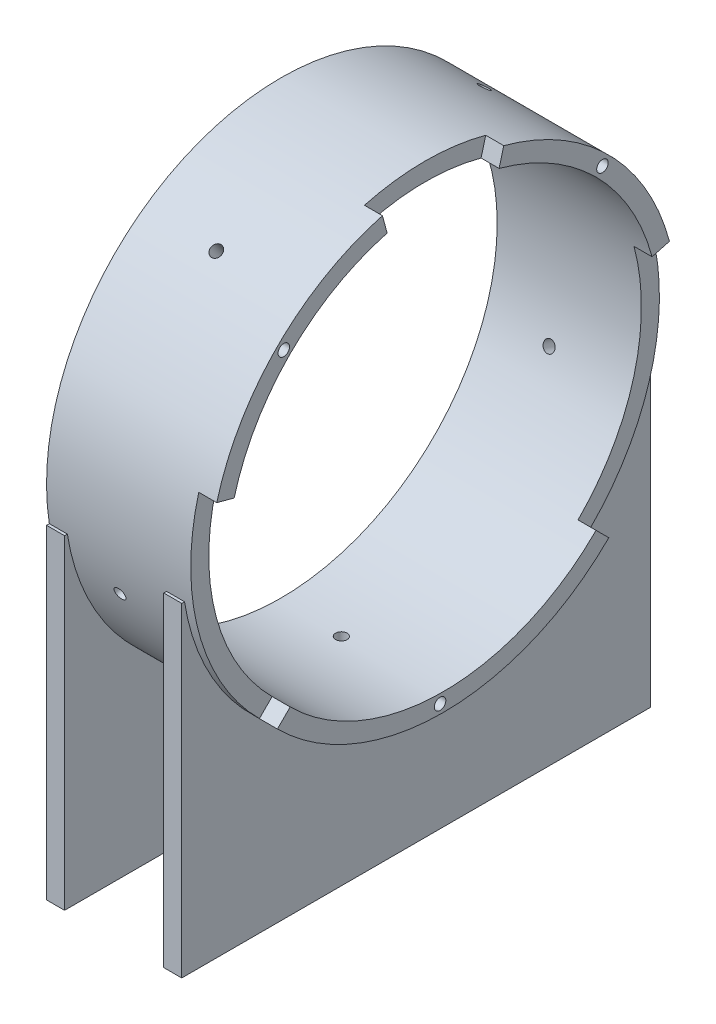
from build123d import *

# Parameters (mm, degrees)
SKETCH1_3_R                       = 260
SKETCH1_3_R_2                     = 240
BOSS_EXTRUDE1_DEPTH               = 180
BOSS_EXTRUDE2_DEPTH               = 20
BOSS_EXTRUDE3_DEPTH               = 20
CUT_EXTRUDE1_DEPTH                = 20
F_1_2_13_TAPPED_HOLE1_AT_2_COUNT  = 2
F_1_2_13_TAPPED_HOLE1_AT_2_PITCH  = 353.553390593
F_1_2_13_TAPPED_HOLE1_AT_3_COUNT  = 2
F_1_2_13_TAPPED_HOLE1_AT_3_PITCH  = 463.112622797
F_1_2_13_TAPPED_HOLE7_D           = 10.71626
F_1_2_13_TAPPED_HOLE7_DEPTH       = 45.9
F_1_2_13_TAPPED_HOLE7_CBORE_D     = 12.7
F_1_2_13_TAPPED_HOLE7_CBORE_DEPTH = 40
F_1_2_13_TAPPED_HOLE7_TIP         = 3.219489309


with BuildPart() as part:
    # Sketch1_3 → Boss-Extrude1 (new body)
    with BuildSketch(Plane(origin=(0, 0, 0), x_dir=(0, 0, -1), z_dir=(1, 0, 0))):
        with Locations(Location((0, 0, 0), (0, 0, 180))):
            Circle(SKETCH1_3_R)
        with Locations(Location((0, 0, 0), (0, 0, 180))):
            Circle(SKETCH1_3_R_2, mode=Mode.SUBTRACT)
    extrude(amount=BOSS_EXTRUDE1_DEPTH)

    # Sketch6 → Boss-Extrude2 (add)
    with BuildSketch(Plane(origin=(0, 0, 0), x_dir=(0, 0, -1), z_dir=(1, 0, 0))):
        with BuildLine():
            Line((-260, -40), (-260, -400))
            Line((-260, -400), (260, -400))
            Line((260, -400), (260, -40))
            Line((260, -40), (256.904651573, -40))
            ThreePointArc((256.904651573, -40), (0, -260), (-256.904651573, -40))
            Line((-256.904651573, -40), (-260, -40))
        make_face()
    extrude(amount=BOSS_EXTRUDE2_DEPTH)

    # Sketch11 → Boss-Extrude3 (add)
    with BuildSketch(Plane(origin=(150, 0, 0), x_dir=(0, 0, -1), z_dir=(1, 0, 0))):
        with BuildLine():
            Line((-260, -40), (-260, -400))
            Line((-260, -400), (260, -400))
            Line((260, -400), (260, -40))
            Line((260, -40), (256.904651573, -40))
            ThreePointArc((256.904651573, -40), (0, -260), (-256.904651573, -40))
            Line((-256.904651573, -40), (-260, -40))
        make_face()
    extrude(amount=-BOSS_EXTRUDE3_DEPTH)

    # Sketch23 → 1_2-13 Tapped Hole6 (revolve, cut)
    with BuildSketch(Plane(origin=(70.297889329, -259.97605488, 3.528581758), x_dir=(0, -0.013571468301340803, -0.9999079033831796), z_dir=(1, 0, 0))):
        Polygon((0, 0), (0, 33.219489309), (5.35813, 30), (5.35813, 40), (6.35, 40), (6.35, 0), align=None)
    revolve(axis=Axis((70.297889329, -266.325470066, 3.614760582), (0, 0.9999079033831795, -0.013571468301340804)), mode=Mode.SUBTRACT)

    # Sketch23 at point 2 (carried to point 2, square into its face) → 1_2-13 Tapped Hole6 at 2 (revolve, cut)
    with BuildSketch(Plane(origin=(69.980761371, -76.555334809, 248.473903483), x_dir=(0, -0.955668758, -0.294443925), z_dir=(1, 0, 0))):
        Polygon((0, 0), (0, 33.219489309), (5.35813, 30), (5.35813, 40), (6.35, 40), (6.35, 0), align=None)
    revolve(axis=Axis((69.980761371, -78.425053736, 254.542400096), (0, 0.294443925, -0.955668758)), mode=Mode.SUBTRACT)

    # Sketch23 at point 3 (carried to point 3, square into its face) → 1_2-13 Tapped Hole6 at 3 (revolve, cut)
    with BuildSketch(Plane(origin=(70.133454805, 208.161719285, -155.784141119), x_dir=(0, 0.599169917, 0.80062189), z_dir=(1, 0, 0))):
        Polygon((0, 0), (0, 33.219489309), (5.35813, 30), (5.35813, 40), (6.35, 40), (6.35, 0), align=None)
    revolve(axis=Axis((70.133454805, 213.245668284, -159.588870095), (0, -0.80062189, 0.599169917)), mode=Mode.SUBTRACT)

    # Sketch23 at point 4 (carried to point 4, square into its face) → 1_2-13 Tapped Hole6 at 4 (revolve, cut)
    with BuildSketch(Plane(origin=(70.173353325, -83.043025916, -246.38152497), x_dir=(0, 0.947621301, -0.319396101), z_dir=(1, 0, 0))):
        Polygon((0, 0), (0, 33.219489309), (5.35813, 30), (5.35813, 40), (6.35, 40), (6.35, 0), align=None)
    revolve(axis=Axis((70.173353325, -85.071191161, -252.398920232), (0, 0.319396101, 0.947621301)), mode=Mode.SUBTRACT)

    # Sketch23 at point 5 (carried to point 5, square into its face) → 1_2-13 Tapped Hole6 at 5 (revolve, cut)
    with BuildSketch(Plane(origin=(81.046534223, 210.414311033, 152.72792054), x_dir=(0, -0.587414938, 0.809285914), z_dir=(1, 0, 0))):
        Polygon((0, 0), (0, 33.219489309), (5.35813, 30), (5.35813, 40), (6.35, 40), (6.35, 0), align=None)
    revolve(axis=Axis((81.046534223, 215.553276588, 156.458005394), (0, -0.809285914, -0.587414938)), mode=Mode.SUBTRACT)

    # Sketch25 → Cut-Extrude1 (cut)
    with BuildSketch(Plane(origin=(180, 0, 0), x_dir=(0, 0, -1), z_dir=(1, 0, 0))):
        with BuildLine():
            Line((-169.705627485, -169.705627485), (-183.847763109, -183.847763109))
            ThreePointArc((-183.847763109, -183.847763109), (-225.166604984, -130), (-251.140714835, -67.292951727))
            ThreePointArc((-251.140714835, -67.292951727), (-260, 0), (-251.140714835, 67.292951727))
            Line((-251.140714835, 67.292951727), (-231.822198309, 62.116570825))
            ThreePointArc((-231.822198309, 62.116570825), (-240, 0), (-231.822198309, -62.116570825))
            ThreePointArc((-231.822198309, -62.116570825), (-207.846096908, -120), (-169.705627485, -169.705627485))
        make_face()
        with BuildLine():
            Line((169.705627485, -169.705627485), (183.847763109, -183.847763109))
            ThreePointArc((183.847763109, -183.847763109), (225.166604984, -130), (251.140714835, -67.292951727))
            ThreePointArc((251.140714835, -67.292951727), (260, 0), (251.140714835, 67.292951727))
            Line((251.140714835, 67.292951727), (231.822198309, 62.116570825))
            ThreePointArc((231.822198309, 62.116570825), (240, 0), (231.822198309, -62.116570825))
            ThreePointArc((231.822198309, -62.116570825), (207.846096908, -120), (169.705627485, -169.705627485))
        make_face()
        with BuildLine():
            Line((62.116570825, 231.822198309), (67.292951727, 251.140714835))
            ThreePointArc((67.292951727, 251.140714835), (0, 260), (-67.292951727, 251.140714835))
            Line((-67.292951727, 251.140714835), (-62.116570825, 231.822198309))
            ThreePointArc((-62.116570825, 231.822198309), (0, 240), (62.116570825, 231.822198309))
        make_face()
    extrude(amount=-CUT_EXTRUDE1_DEPTH, mode=Mode.SUBTRACT)

    # Sketch31 → 1_2-13 Tapped Hole1 (revolve, cut)
    with BuildSketch(Plane(origin=(180, 176.776695297, -176.776695297), x_dir=(0, 0, -1), z_dir=(0, 1, 0))):
        Polygon((0, 0), (0, 53.219489309), (5.35813, 50), (5.35813, 64.5), (6.35, 64.5), (6.35, 0), align=None)
    f_1_2_13_tapped_hole1 = revolve(axis=Axis((186.35, 176.776695297, -176.776695297), (-1, 0, 0)), mode=Mode.SUBTRACT)

    # 1_2-13 Tapped Hole1 at 2: 1_2-13 Tapped Hole1 ×2
    with Locations(*[(0, 0, i * F_1_2_13_TAPPED_HOLE1_AT_2_PITCH) for i in range(1, F_1_2_13_TAPPED_HOLE1_AT_2_COUNT)]):
        add(f_1_2_13_tapped_hole1, mode=Mode.SUBTRACT)

    # 1_2-13 Tapped Hole1 at 3: 1_2-13 Tapped Hole1 ×2
    with Locations(*[Vector(0, -0.9212531823667619, 0.3889634609820231) * (i * F_1_2_13_TAPPED_HOLE1_AT_3_PITCH) for i in range(1, F_1_2_13_TAPPED_HOLE1_AT_3_COUNT)]):
        add(f_1_2_13_tapped_hole1, mode=Mode.SUBTRACT)

    # 1_2-13 Tapped Hole7
    with Locations(Plane(origin=(140, -400, 250), x_dir=(0, 0, -1), z_dir=(0, -1, 0))):
        with Locations((0, 0), (0, -130), (500, -130), (500, 0)):
            CounterBoreHole(F_1_2_13_TAPPED_HOLE7_D / 2, F_1_2_13_TAPPED_HOLE7_CBORE_D / 2, F_1_2_13_TAPPED_HOLE7_CBORE_DEPTH, depth=F_1_2_13_TAPPED_HOLE7_DEPTH)
            with Locations((0, 0, -(F_1_2_13_TAPPED_HOLE7_DEPTH + F_1_2_13_TAPPED_HOLE7_TIP / 2))):  # 118° drill point
                Cone(0, F_1_2_13_TAPPED_HOLE7_D / 2, F_1_2_13_TAPPED_HOLE7_TIP, mode=Mode.SUBTRACT)


solid = part.part
